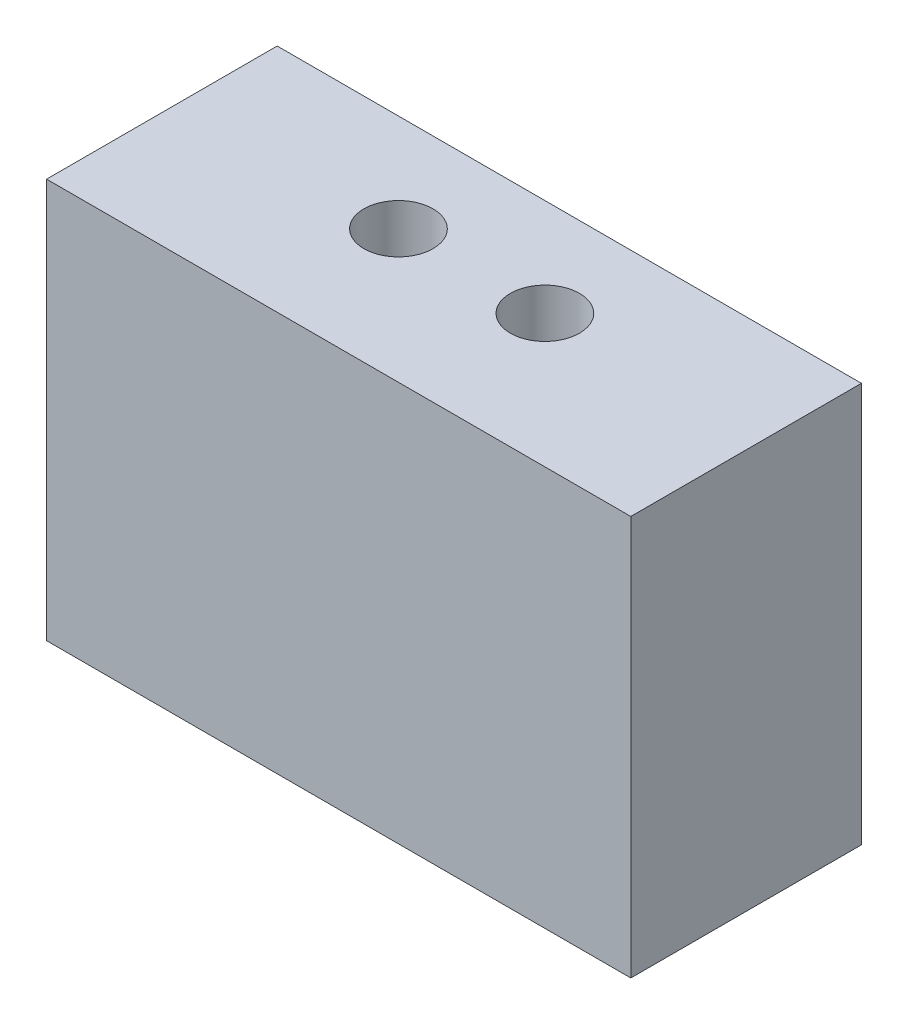
from build123d import *

# Parameters (mm, degrees)
SKETCH1_W             = 38
SKETCH1_H             = 52
EXTRUDE1_DEPTH        = 15
SKETCH4_W             = 38
SKETCH4_H             = 26
CUT_EXTRUDE3_DEPTH    = 16
F_8_CLEARANCE_HOLE2_D = 4.4958


with BuildPart() as part:
    # Sketch1 → Extrude1 (new body)
    with BuildSketch(Plane.XY):
        with Locations((0, 26)):
            Rectangle(SKETCH1_W, SKETCH1_H)
    extrude(amount=EXTRUDE1_DEPTH)

    # Sketch4 → Cut-Extrude3 (cut, through all)
    with BuildSketch(Plane.XY.offset(15)):
        with Locations((0, 39)):
            Rectangle(SKETCH4_W, SKETCH4_H)
    extrude(amount=-CUT_EXTRUDE3_DEPTH, mode=Mode.SUBTRACT)

    # #8 Clearance Hole2 (through all)
    with Locations(Plane(origin=(0, 26, 0), x_dir=(-1, 0, 0), z_dir=(0, 1, 0))):
        with Locations((-4.7625, 6.35), (4.7625, 6.35)):
            Hole(F_8_CLEARANCE_HOLE2_D / 2)


solid = part.part
